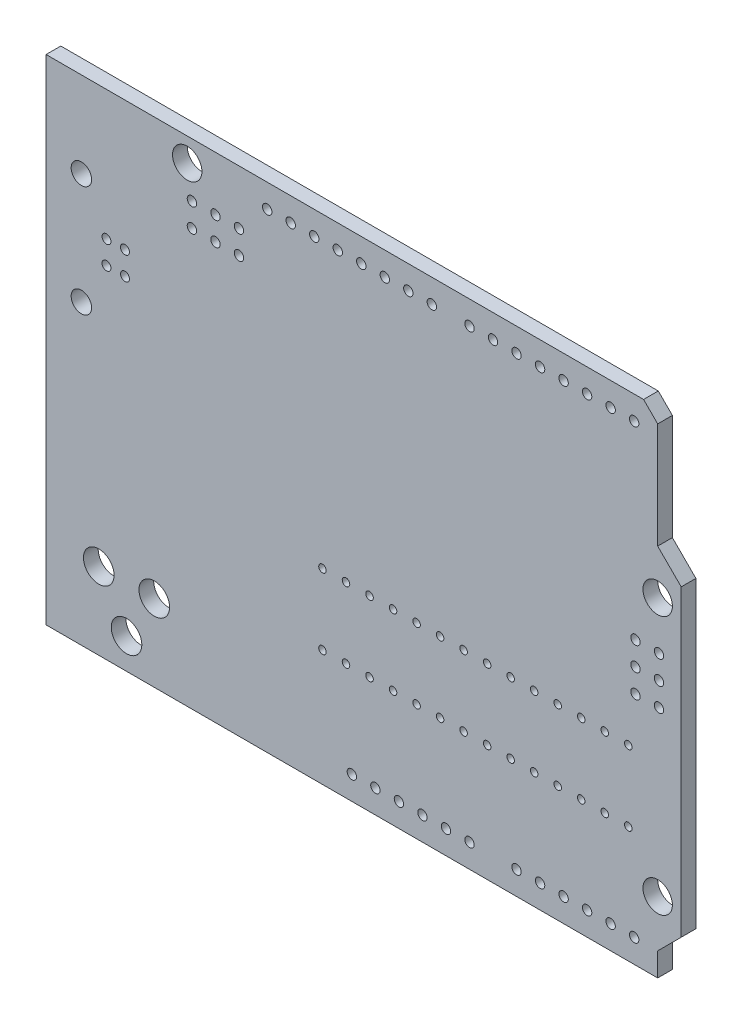
from build123d import *

# Parameters (mm, degrees)
BOSS_EXTRUDE1_DEPTH = 1.5875
SKETCH3_R           = 1.1049
SKETCH3_R_2         = 1.651
SKETCH3_R_3         = 1.5875
SKETCH3_R_4         = 0.4826
CUT_EXTRUDE1_DEPTH  = 2.5875
SKETCH4_R           = 0.508
SKETCH4_R_2         = 0.4064
CUT_EXTRUDE2_DEPTH  = 2.5875


with BuildPart() as part:
    # Sketch2 → Boss-Extrude1 (new body)
    with BuildSketch(Plane.XY):
        Polygon((-34.2899492, 26.67), (30.2259492, 26.67), (31.7499492, 25.146), (31.7499492, 13.716), (34.2899492, 11.176), (34.2899492, -21.59), (31.7499492, -24.13), (31.7499492, -26.67), (-34.2899492, -26.67), align=None)
    extrude(amount=-BOSS_EXTRUDE1_DEPTH)

    # Sketch3 → Cut-Extrude1 (cut, through all)
    with BuildSketch(Plane.XY):
        with Locations((-30.4799492, 17.429988)):
            Circle(SKETCH3_R)
        with Locations((-30.4799492, 5.430012)):
            Circle(SKETCH3_R)
        with Locations((-28.6003492, -18.3642)):
            Circle(SKETCH3_R_2)
        with Locations((-25.6031492, -23.368)):
            Circle(SKETCH3_R_2)
        with Locations((-22.6060508, -18.3642)):
            Circle(SKETCH3_R_2)
        with Locations((31.7499492, -19.05)):
            Circle(SKETCH3_R_3)
        with Locations((31.7499492, 8.89)):
            Circle(SKETCH3_R_3)
        with Locations((-19.0500508, 24.13)):
            Circle(SKETCH3_R_3)
        with Locations((-25.769951, 12.679934)):
            Circle(SKETCH3_R_4)
        with Locations((-27.769947, 12.679934)):
            Circle(SKETCH3_R_4)
        with Locations((-27.769947, 10.180066)):
            Circle(SKETCH3_R_4)
        with Locations((-25.769951, 10.180066)):
            Circle(SKETCH3_R_4)
    extrude(amount=-CUT_EXTRUDE1_DEPTH, mode=Mode.SUBTRACT)

    # Sketch4 → Cut-Extrude2 (cut, through all)
    with BuildSketch(Plane.XY):
        with Locations((29.2099492, 24.13)):
            Circle(SKETCH4_R)
        with Locations((26.6699492, 24.13)):
            Circle(SKETCH4_R)
        with Locations((24.1299492, 24.13)):
            Circle(SKETCH4_R)
        with Locations((21.5899492, 24.13)):
            Circle(SKETCH4_R)
        with Locations((19.0499492, 24.13)):
            Circle(SKETCH4_R)
        with Locations((16.5099492, 24.13)):
            Circle(SKETCH4_R)
        with Locations((13.9699492, 24.13)):
            Circle(SKETCH4_R)
        with Locations((11.4299492, 24.13)):
            Circle(SKETCH4_R)
        with Locations((7.3659492, 24.13)):
            Circle(SKETCH4_R)
        with Locations((4.8259492, 24.13)):
            Circle(SKETCH4_R)
        with Locations((2.2859492, 24.13)):
            Circle(SKETCH4_R)
        with Locations((-0.2540508, 24.13)):
            Circle(SKETCH4_R)
        with Locations((-2.7940508, 24.13)):
            Circle(SKETCH4_R)
        with Locations((-5.3340508, 24.13)):
            Circle(SKETCH4_R)
        with Locations((-7.8740508, 24.13)):
            Circle(SKETCH4_R)
        with Locations((-10.4140508, 24.13)):
            Circle(SKETCH4_R)
        with Locations((28.5749492, -6.477)):
            Circle(SKETCH4_R_2)
        with Locations((26.0349492, -6.477)):
            Circle(SKETCH4_R_2)
        with Locations((23.4949492, -6.477)):
            Circle(SKETCH4_R_2)
        with Locations((20.9549492, -6.477)):
            Circle(SKETCH4_R_2)
        with Locations((18.4149492, -6.477)):
            Circle(SKETCH4_R_2)
        with Locations((15.8749492, -6.477)):
            Circle(SKETCH4_R_2)
        with Locations((13.3349492, -6.477)):
            Circle(SKETCH4_R_2)
        with Locations((10.7949492, -6.477)):
            Circle(SKETCH4_R_2)
        with Locations((8.2549492, -6.477)):
            Circle(SKETCH4_R_2)
        with Locations((5.7149492, -6.477)):
            Circle(SKETCH4_R_2)
        with Locations((3.1749492, -6.477)):
            Circle(SKETCH4_R_2)
        with Locations((0.6349492, -6.477)):
            Circle(SKETCH4_R_2)
        with Locations((-1.9050508, -6.477)):
            Circle(SKETCH4_R_2)
        with Locations((-4.4450508, -6.477)):
            Circle(SKETCH4_R_2)
        with Locations((28.5749492, -14.097)):
            Circle(SKETCH4_R_2)
        with Locations((26.0349492, -14.097)):
            Circle(SKETCH4_R_2)
        with Locations((23.4949492, -14.097)):
            Circle(SKETCH4_R_2)
        with Locations((20.9549492, -14.097)):
            Circle(SKETCH4_R_2)
        with Locations((18.4149492, -14.097)):
            Circle(SKETCH4_R_2)
        with Locations((15.8749492, -14.097)):
            Circle(SKETCH4_R_2)
        with Locations((13.3349492, -14.097)):
            Circle(SKETCH4_R_2)
        with Locations((10.7949492, -14.097)):
            Circle(SKETCH4_R_2)
        with Locations((8.2549492, -14.097)):
            Circle(SKETCH4_R_2)
        with Locations((5.7149492, -14.097)):
            Circle(SKETCH4_R_2)
        with Locations((3.1749492, -14.097)):
            Circle(SKETCH4_R_2)
        with Locations((0.6349492, -14.097)):
            Circle(SKETCH4_R_2)
        with Locations((-1.9050508, -14.097)):
            Circle(SKETCH4_R_2)
        with Locations((-4.4450508, -14.097)):
            Circle(SKETCH4_R_2)
        with Locations((29.2099492, -24.13)):
            Circle(SKETCH4_R)
        with Locations((11.4299492, -24.13)):
            Circle(SKETCH4_R)
        with Locations((26.6699492, -24.13)):
            Circle(SKETCH4_R)
        with Locations((8.8899492, -24.13)):
            Circle(SKETCH4_R)
        with Locations((24.1299492, -24.13)):
            Circle(SKETCH4_R)
        with Locations((6.3499492, -24.13)):
            Circle(SKETCH4_R)
        with Locations((21.5899492, -24.13)):
            Circle(SKETCH4_R)
        with Locations((3.8099492, -24.13)):
            Circle(SKETCH4_R)
        with Locations((19.0499492, -24.13)):
            Circle(SKETCH4_R)
        with Locations((1.2699492, -24.13)):
            Circle(SKETCH4_R)
        with Locations((16.5099492, -24.13)):
            Circle(SKETCH4_R)
        with Locations((-1.2700508, -24.13)):
            Circle(SKETCH4_R)
        with Locations((-13.4620508, 20.828)):
            Circle(SKETCH4_R)
        with Locations((-13.4620508, 18.288)):
            Circle(SKETCH4_R)
        with Locations((-16.0020508, 18.288)):
            Circle(SKETCH4_R)
        with Locations((-16.0020508, 20.828)):
            Circle(SKETCH4_R)
        with Locations((-18.5420508, 18.288)):
            Circle(SKETCH4_R)
        with Locations((-18.5420508, 20.828)):
            Circle(SKETCH4_R)
        with Locations((31.8901572, -1.320038)):
            Circle(SKETCH4_R)
        with Locations((29.3501572, -1.320038)):
            Circle(SKETCH4_R)
        with Locations((29.3501572, 1.219962)):
            Circle(SKETCH4_R)
        with Locations((31.8901572, 1.219962)):
            Circle(SKETCH4_R)
        with Locations((29.3501572, 3.759962)):
            Circle(SKETCH4_R)
        with Locations((31.8901572, 3.759962)):
            Circle(SKETCH4_R)
    extrude(amount=-CUT_EXTRUDE2_DEPTH, mode=Mode.SUBTRACT)


solid = part.part
